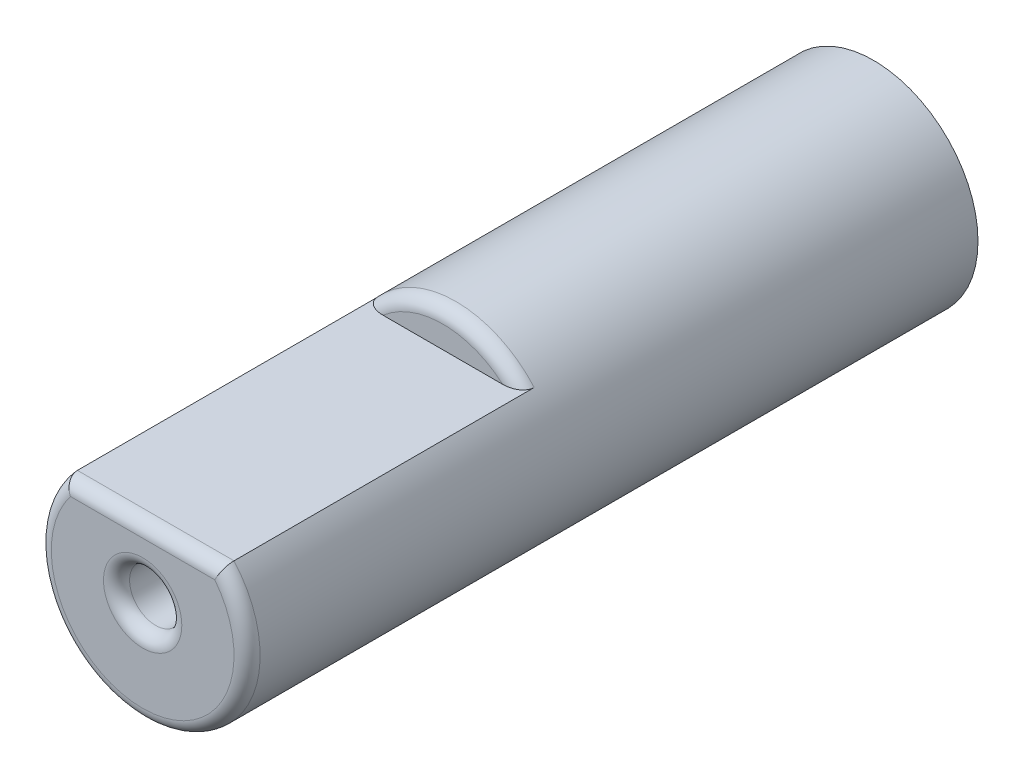
from build123d import *

# Parameters (mm, degrees)
SKETCH1_R           = 4
BOSS_EXTRUDE1_DEPTH = 28
CUT_EXTRUDE1_DEPTH  = 11.5
SKETCH3_R           = 1
CUT_EXTRUDE2_DEPTH  = 4
FILLET1_R           = 0.5


with BuildPart() as part:
    # Sketch1 → Boss-Extrude1 (new body)
    with BuildSketch(Plane.XY):
        Circle(SKETCH1_R)
    extrude(amount=BOSS_EXTRUDE1_DEPTH)

    # Sketch2 → Cut-Extrude1 (cut)
    with BuildSketch(Plane.XY.offset(28)):
        with BuildLine():
            Line((-3, 2.645751311), (3, 2.645751311))
            ThreePointArc((3, 2.645751311), (0, 4), (-3, 2.645751311))
        make_face()
    extrude(amount=-CUT_EXTRUDE1_DEPTH, mode=Mode.SUBTRACT)

    # Sketch3 → Cut-Extrude2 (cut)
    with BuildSketch(Plane.XY.offset(28)):
        Circle(SKETCH3_R)
    extrude(amount=-CUT_EXTRUDE2_DEPTH, mode=Mode.SUBTRACT)

    # Fillet1
    fillet1_edges = [part.edges().sort_by_distance(p)[0] for p in [
        (-1, 0, 28),
        (-1.414213562, -3.741657387, 28),
        (0, 4, 16.5),
        (0, 2.645751311, 28),
    ]]
    fillet(fillet1_edges, radius=FILLET1_R)


solid = part.part
